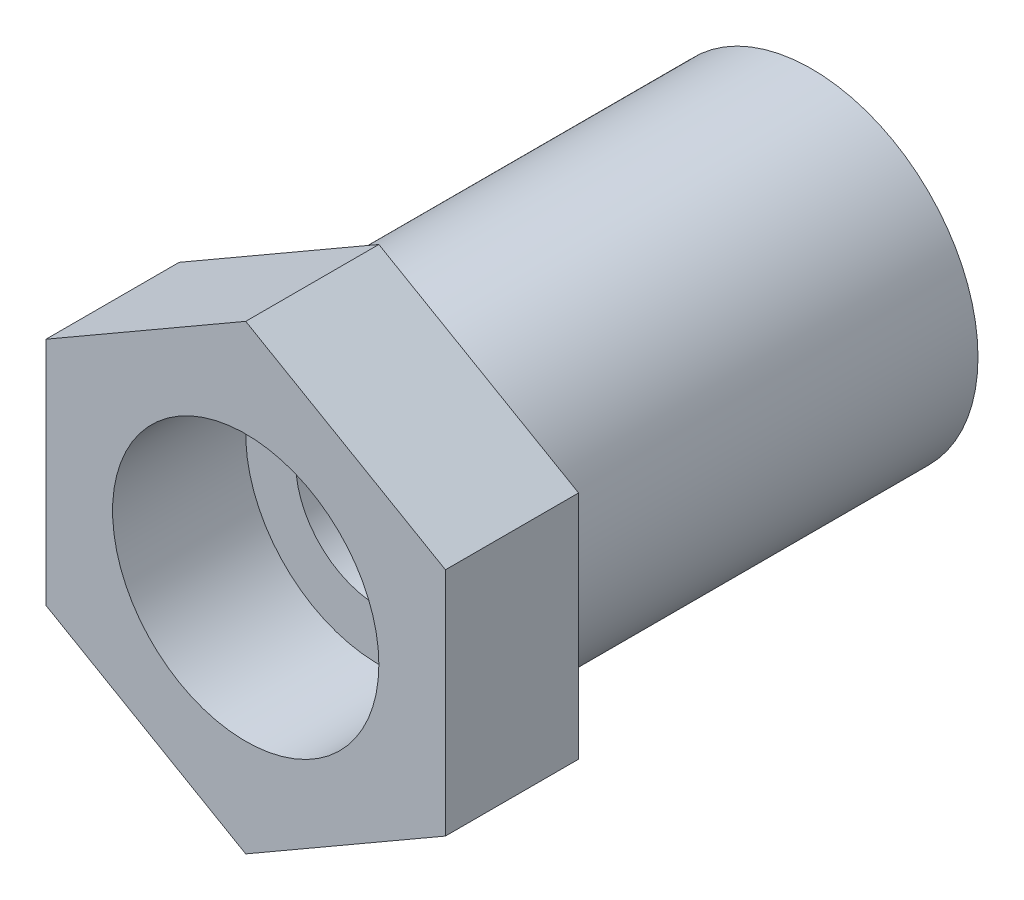
from build123d import *

# Parameters (mm, degrees)
SKETCH2_R           = 5
BOSS_EXTRUDE1_DEPTH = 13
BOSS_EXTRUDE2_DEPTH = 4
SKETCH4_R           = 2.5
CUT_EXTRUDE1_DEPTH  = 13
SKETCH5_R           = 4
CUT_EXTRUDE2_DEPTH  = 4


with BuildPart() as part:
    # Sketch2 → Boss-Extrude1 (new body)
    with BuildSketch(Plane.XY):
        with Locations((-29.060949788, 5.337240829)):
            Circle(SKETCH2_R)
    extrude(amount=BOSS_EXTRUDE1_DEPTH)

    # Sketch3 → Boss-Extrude2 (add)
    with BuildSketch(Plane.XY.offset(13)):
        Polygon((-29.060949788, -1.590962401), (-23.060949788, 1.873139214), (-23.060949788, 8.801342444), (-29.060949788, 12.26544406), (-35.060949788, 8.801342444), (-35.060949788, 1.873139214), align=None)
    extrude(amount=BOSS_EXTRUDE2_DEPTH)

    # Sketch4 → Cut-Extrude1 (cut)
    with BuildSketch(Plane(origin=(0, 0, 0), x_dir=(-1, 0, 0), z_dir=(0, 0, -1))):
        with Locations((29.060949788, 5.337240829)):
            Circle(SKETCH4_R)
    extrude(amount=-CUT_EXTRUDE1_DEPTH, mode=Mode.SUBTRACT)

    # Sketch5 → Cut-Extrude2 (cut)
    with BuildSketch(Plane.XY.offset(17)):
        with Locations((-29.060949788, 5.337240829)):
            Circle(SKETCH5_R)
    extrude(amount=-CUT_EXTRUDE2_DEPTH, mode=Mode.SUBTRACT)


solid = part.part
